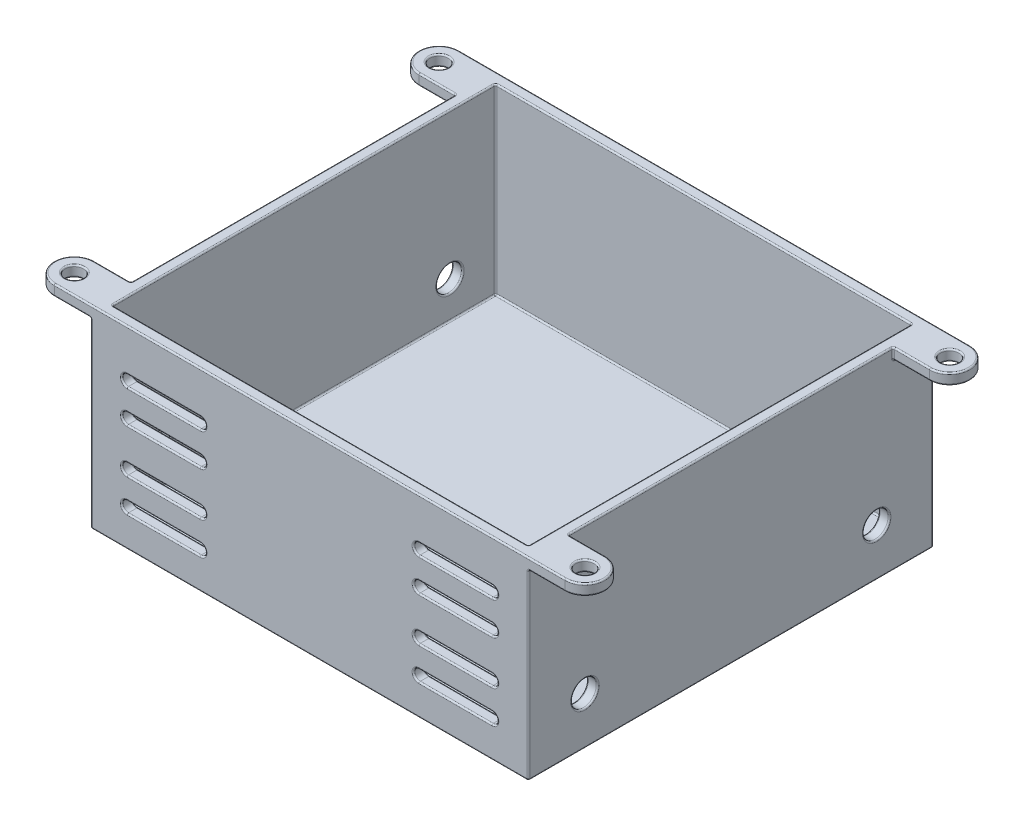
from build123d import *

# Parameters (mm, degrees)
SKETCH8_W                      = 60
SKETCH8_H                      = 55.5
SKETCH8_W_2                    = 57
SKETCH8_H_2                    = 52.5
BOSS_EXTRUDE4_DEPTH            = 25
SKETCH9_W                      = 60
SKETCH9_H                      = 55.5
BOSS_EXTRUDE5_DEPTH            = 1.5
SKETCH10_R                     = 1.25
BOSS_EXTRUDE6_DEPTH            = 1.5
CUT_EXTRUDE1_REACH             = 29.75
CUT_EXTRUDE1_DIRECTION_2_REACH = 29.75
CUT_EXTRUDE2_REACH             = 39.75
SKETCH14_R                     = 1.75
CUT_EXTRUDE2_DIRECTION_2_REACH = 39.75
FILLET1_R                      = 0.2


with BuildPart() as part:
    # Sketch8 → Boss-Extrude4 (new body)
    with BuildSketch(Plane(origin=(0, 0, 0), x_dir=(1, 0, 0), z_dir=(0, 1, 0))):
        Rectangle(SKETCH8_W, SKETCH8_H)
        Rectangle(SKETCH8_W_2, SKETCH8_H_2, mode=Mode.SUBTRACT)
    extrude(amount=-BOSS_EXTRUDE4_DEPTH)

    # Sketch9 → Boss-Extrude5 (add)
    with BuildSketch(Plane.XZ.offset(25)):
        Rectangle(SKETCH9_W, SKETCH9_H)
    extrude(amount=BOSS_EXTRUDE5_DEPTH)

    # Sketch10 → Boss-Extrude6 (add)
    with BuildSketch(Plane(origin=(0, 0, 0), x_dir=(1, 0, 0), z_dir=(0, 1, 0))):
        with BuildLine():
            Line((-30, -22.25), (-30, -27.75))
            Line((-30, -27.75), (-35, -27.75))
            ThreePointArc((-35, -27.75), (-37.75, -25), (-35, -22.25))
            Line((-35, -22.25), (-30, -22.25))
        make_face()
        with Locations((-35, -25)):
            Circle(SKETCH10_R, mode=Mode.SUBTRACT)
        with BuildLine():
            Line((30, -27.75), (30, -22.25))
            Line((30, -22.25), (35, -22.25))
            ThreePointArc((35, -22.25), (37.75, -25), (35, -27.75))
            Line((35, -27.75), (30, -27.75))
        make_face()
        with Locations((35, -25)):
            Circle(SKETCH10_R, mode=Mode.SUBTRACT)
        with BuildLine():
            Line((35, 22.25), (30, 22.25))
            Line((30, 22.25), (30, 27.75))
            Line((30, 27.75), (35, 27.75))
            ThreePointArc((35, 27.75), (37.75, 25), (35, 22.25))
        make_face()
        with Locations((35, 25)):
            Circle(SKETCH10_R, mode=Mode.SUBTRACT)
        with BuildLine():
            Line((-35, 22.25), (-30, 22.25))
            Line((-30, 22.25), (-30, 27.75))
            Line((-30, 27.75), (-35, 27.75))
            ThreePointArc((-35, 27.75), (-37.75, 25), (-35, 22.25))
        make_face()
        with Locations((-35, 25)):
            Circle(SKETCH10_R, mode=Mode.SUBTRACT)
    extrude(amount=-BOSS_EXTRUDE6_DEPTH)

    # Cut-Extrude1: up to this face of the body (flat: up to its plane)
    cut_extrude1_end = Plane(part.part.faces().sort_by_distance((0, -13.13317757, 27.75))[0])
    # Sketch13 → Cut-Extrude1 (cut, up to the picked face)
    with BuildSketch(Plane.XY, mode=Mode.PRIVATE) as cut_extrude1_sk1:
        with BuildLine():
            Line((-25, -5.75), (-15, -5.75))
            ThreePointArc((-15, -5.75), (-14.25, -6.5), (-15, -7.25))
            Line((-15, -7.25), (-25, -7.25))
            ThreePointArc((-25, -7.25), (-25.75, -6.5), (-25, -5.75))
        make_face()
    cut_extrude1_tool1 = split(extrude(cut_extrude1_sk1.sketch, amount=CUT_EXTRUDE1_REACH, mode=Mode.PRIVATE), bisect_by=cut_extrude1_end, keep=Keep.BOTH, mode=Mode.PRIVATE)
    add(cut_extrude1_tool1.solids().sort_by_distance((-20, -6.5, 0))[0], mode=Mode.SUBTRACT)
    # Sketch13 → Cut-Extrude1 (cut, up to the picked face)
    with BuildSketch(Plane.XY, mode=Mode.PRIVATE) as cut_extrude1_sk2:
        with BuildLine():
            Line((-25, -10.25), (-15, -10.25))
            ThreePointArc((-15, -10.25), (-14.25, -11), (-15, -11.75))
            Line((-15, -11.75), (-25, -11.75))
            ThreePointArc((-25, -11.75), (-25.75, -11), (-25, -10.25))
        make_face()
    cut_extrude1_tool2 = split(extrude(cut_extrude1_sk2.sketch, amount=CUT_EXTRUDE1_REACH, mode=Mode.PRIVATE), bisect_by=cut_extrude1_end, keep=Keep.BOTH, mode=Mode.PRIVATE)
    add(cut_extrude1_tool2.solids().sort_by_distance((-20, -11, 0))[0], mode=Mode.SUBTRACT)
    # Sketch13 → Cut-Extrude1 (cut, up to the picked face)
    with BuildSketch(Plane.XY, mode=Mode.PRIVATE) as cut_extrude1_sk3:
        with BuildLine():
            Line((-25, -22.25), (-15, -22.25))
            ThreePointArc((-15, -22.25), (-14.25, -21.5), (-15, -20.75))
            Line((-15, -20.75), (-25, -20.75))
            ThreePointArc((-25, -20.75), (-25.75, -21.5), (-25, -22.25))
        make_face()
    cut_extrude1_tool3 = split(extrude(cut_extrude1_sk3.sketch, amount=CUT_EXTRUDE1_REACH, mode=Mode.PRIVATE), bisect_by=cut_extrude1_end, keep=Keep.BOTH, mode=Mode.PRIVATE)
    add(cut_extrude1_tool3.solids().sort_by_distance((-20, -21.5, 0))[0], mode=Mode.SUBTRACT)
    # Sketch13 → Cut-Extrude1 (cut, up to the picked face)
    with BuildSketch(Plane.XY, mode=Mode.PRIVATE) as cut_extrude1_sk4:
        with BuildLine():
            Line((-25, -17.75), (-15, -17.75))
            ThreePointArc((-15, -17.75), (-14.25, -17), (-15, -16.25))
            Line((-15, -16.25), (-25, -16.25))
            ThreePointArc((-25, -16.25), (-25.75, -17), (-25, -17.75))
        make_face()
    cut_extrude1_tool4 = split(extrude(cut_extrude1_sk4.sketch, amount=CUT_EXTRUDE1_REACH, mode=Mode.PRIVATE), bisect_by=cut_extrude1_end, keep=Keep.BOTH, mode=Mode.PRIVATE)
    add(cut_extrude1_tool4.solids().sort_by_distance((-20, -17, 0))[0], mode=Mode.SUBTRACT)
    # Sketch13 → Cut-Extrude1 (cut, up to the picked face)
    with BuildSketch(Plane.XY, mode=Mode.PRIVATE) as cut_extrude1_sk5:
        with BuildLine():
            Line((25, -5.75), (15, -5.75))
            ThreePointArc((15, -5.75), (14.25, -6.5), (15, -7.25))
            Line((15, -7.25), (25, -7.25))
            ThreePointArc((25, -7.25), (25.75, -6.5), (25, -5.75))
        make_face()
    cut_extrude1_tool5 = split(extrude(cut_extrude1_sk5.sketch, amount=CUT_EXTRUDE1_REACH, mode=Mode.PRIVATE), bisect_by=cut_extrude1_end, keep=Keep.BOTH, mode=Mode.PRIVATE)
    add(cut_extrude1_tool5.solids().sort_by_distance((20, -6.5, 0))[0], mode=Mode.SUBTRACT)
    # Sketch13 → Cut-Extrude1 (cut, up to the picked face)
    with BuildSketch(Plane.XY, mode=Mode.PRIVATE) as cut_extrude1_sk6:
        with BuildLine():
            Line((25, -10.25), (15, -10.25))
            ThreePointArc((15, -10.25), (14.25, -11), (15, -11.75))
            Line((15, -11.75), (25, -11.75))
            ThreePointArc((25, -11.75), (25.75, -11), (25, -10.25))
        make_face()
    cut_extrude1_tool6 = split(extrude(cut_extrude1_sk6.sketch, amount=CUT_EXTRUDE1_REACH, mode=Mode.PRIVATE), bisect_by=cut_extrude1_end, keep=Keep.BOTH, mode=Mode.PRIVATE)
    add(cut_extrude1_tool6.solids().sort_by_distance((20, -11, 0))[0], mode=Mode.SUBTRACT)
    # Sketch13 → Cut-Extrude1 (cut, up to the picked face)
    with BuildSketch(Plane.XY, mode=Mode.PRIVATE) as cut_extrude1_sk7:
        with BuildLine():
            Line((25, -22.25), (15, -22.25))
            ThreePointArc((15, -22.25), (14.25, -21.5), (15, -20.75))
            Line((15, -20.75), (25, -20.75))
            ThreePointArc((25, -20.75), (25.75, -21.5), (25, -22.25))
        make_face()
    cut_extrude1_tool7 = split(extrude(cut_extrude1_sk7.sketch, amount=CUT_EXTRUDE1_REACH, mode=Mode.PRIVATE), bisect_by=cut_extrude1_end, keep=Keep.BOTH, mode=Mode.PRIVATE)
    add(cut_extrude1_tool7.solids().sort_by_distance((20, -21.5, 0))[0], mode=Mode.SUBTRACT)
    # Sketch13 → Cut-Extrude1 (cut, up to the picked face)
    with BuildSketch(Plane.XY, mode=Mode.PRIVATE) as cut_extrude1_sk8:
        with BuildLine():
            Line((25, -17.75), (15, -17.75))
            ThreePointArc((15, -17.75), (14.25, -17), (15, -16.25))
            Line((15, -16.25), (25, -16.25))
            ThreePointArc((25, -16.25), (25.75, -17), (25, -17.75))
        make_face()
    cut_extrude1_tool8 = split(extrude(cut_extrude1_sk8.sketch, amount=CUT_EXTRUDE1_REACH, mode=Mode.PRIVATE), bisect_by=cut_extrude1_end, keep=Keep.BOTH, mode=Mode.PRIVATE)
    add(cut_extrude1_tool8.solids().sort_by_distance((20, -17, 0))[0], mode=Mode.SUBTRACT)

    # Cut-Extrude1 direction 2: up to this face of the body (flat: up to its plane)
    cut_extrude1_direction_2_end = Plane(part.part.faces().sort_by_distance((0, -12.5, -26.25))[0])
    # Sketch13 → Cut-Extrude1 direction 2 (cut, up to the picked face)
    with BuildSketch(Plane.XY, mode=Mode.PRIVATE) as cut_extrude1_direction_2_sk1:
        with BuildLine():
            Line((-25, -5.75), (-15, -5.75))
            ThreePointArc((-15, -5.75), (-14.25, -6.5), (-15, -7.25))
            Line((-15, -7.25), (-25, -7.25))
            ThreePointArc((-25, -7.25), (-25.75, -6.5), (-25, -5.75))
        make_face()
    cut_extrude1_direction_2_tool1 = split(extrude(cut_extrude1_direction_2_sk1.sketch, amount=-CUT_EXTRUDE1_DIRECTION_2_REACH, mode=Mode.PRIVATE), bisect_by=cut_extrude1_direction_2_end, keep=Keep.BOTH, mode=Mode.PRIVATE)
    add(cut_extrude1_direction_2_tool1.solids().sort_by_distance((-20, -6.5, 0))[0], mode=Mode.SUBTRACT)
    # Sketch13 → Cut-Extrude1 direction 2 (cut, up to the picked face)
    with BuildSketch(Plane.XY, mode=Mode.PRIVATE) as cut_extrude1_direction_2_sk2:
        with BuildLine():
            Line((-25, -10.25), (-15, -10.25))
            ThreePointArc((-15, -10.25), (-14.25, -11), (-15, -11.75))
            Line((-15, -11.75), (-25, -11.75))
            ThreePointArc((-25, -11.75), (-25.75, -11), (-25, -10.25))
        make_face()
    cut_extrude1_direction_2_tool2 = split(extrude(cut_extrude1_direction_2_sk2.sketch, amount=-CUT_EXTRUDE1_DIRECTION_2_REACH, mode=Mode.PRIVATE), bisect_by=cut_extrude1_direction_2_end, keep=Keep.BOTH, mode=Mode.PRIVATE)
    add(cut_extrude1_direction_2_tool2.solids().sort_by_distance((-20, -11, 0))[0], mode=Mode.SUBTRACT)
    # Sketch13 → Cut-Extrude1 direction 2 (cut, up to the picked face)
    with BuildSketch(Plane.XY, mode=Mode.PRIVATE) as cut_extrude1_direction_2_sk3:
        with BuildLine():
            Line((-25, -22.25), (-15, -22.25))
            ThreePointArc((-15, -22.25), (-14.25, -21.5), (-15, -20.75))
            Line((-15, -20.75), (-25, -20.75))
            ThreePointArc((-25, -20.75), (-25.75, -21.5), (-25, -22.25))
        make_face()
    cut_extrude1_direction_2_tool3 = split(extrude(cut_extrude1_direction_2_sk3.sketch, amount=-CUT_EXTRUDE1_DIRECTION_2_REACH, mode=Mode.PRIVATE), bisect_by=cut_extrude1_direction_2_end, keep=Keep.BOTH, mode=Mode.PRIVATE)
    add(cut_extrude1_direction_2_tool3.solids().sort_by_distance((-20, -21.5, 0))[0], mode=Mode.SUBTRACT)
    # Sketch13 → Cut-Extrude1 direction 2 (cut, up to the picked face)
    with BuildSketch(Plane.XY, mode=Mode.PRIVATE) as cut_extrude1_direction_2_sk4:
        with BuildLine():
            Line((-25, -17.75), (-15, -17.75))
            ThreePointArc((-15, -17.75), (-14.25, -17), (-15, -16.25))
            Line((-15, -16.25), (-25, -16.25))
            ThreePointArc((-25, -16.25), (-25.75, -17), (-25, -17.75))
        make_face()
    cut_extrude1_direction_2_tool4 = split(extrude(cut_extrude1_direction_2_sk4.sketch, amount=-CUT_EXTRUDE1_DIRECTION_2_REACH, mode=Mode.PRIVATE), bisect_by=cut_extrude1_direction_2_end, keep=Keep.BOTH, mode=Mode.PRIVATE)
    add(cut_extrude1_direction_2_tool4.solids().sort_by_distance((-20, -17, 0))[0], mode=Mode.SUBTRACT)
    # Sketch13 → Cut-Extrude1 direction 2 (cut, up to the picked face)
    with BuildSketch(Plane.XY, mode=Mode.PRIVATE) as cut_extrude1_direction_2_sk5:
        with BuildLine():
            Line((25, -5.75), (15, -5.75))
            ThreePointArc((15, -5.75), (14.25, -6.5), (15, -7.25))
            Line((15, -7.25), (25, -7.25))
            ThreePointArc((25, -7.25), (25.75, -6.5), (25, -5.75))
        make_face()
    cut_extrude1_direction_2_tool5 = split(extrude(cut_extrude1_direction_2_sk5.sketch, amount=-CUT_EXTRUDE1_DIRECTION_2_REACH, mode=Mode.PRIVATE), bisect_by=cut_extrude1_direction_2_end, keep=Keep.BOTH, mode=Mode.PRIVATE)
    add(cut_extrude1_direction_2_tool5.solids().sort_by_distance((20, -6.5, 0))[0], mode=Mode.SUBTRACT)
    # Sketch13 → Cut-Extrude1 direction 2 (cut, up to the picked face)
    with BuildSketch(Plane.XY, mode=Mode.PRIVATE) as cut_extrude1_direction_2_sk6:
        with BuildLine():
            Line((25, -10.25), (15, -10.25))
            ThreePointArc((15, -10.25), (14.25, -11), (15, -11.75))
            Line((15, -11.75), (25, -11.75))
            ThreePointArc((25, -11.75), (25.75, -11), (25, -10.25))
        make_face()
    cut_extrude1_direction_2_tool6 = split(extrude(cut_extrude1_direction_2_sk6.sketch, amount=-CUT_EXTRUDE1_DIRECTION_2_REACH, mode=Mode.PRIVATE), bisect_by=cut_extrude1_direction_2_end, keep=Keep.BOTH, mode=Mode.PRIVATE)
    add(cut_extrude1_direction_2_tool6.solids().sort_by_distance((20, -11, 0))[0], mode=Mode.SUBTRACT)
    # Sketch13 → Cut-Extrude1 direction 2 (cut, up to the picked face)
    with BuildSketch(Plane.XY, mode=Mode.PRIVATE) as cut_extrude1_direction_2_sk7:
        with BuildLine():
            Line((25, -22.25), (15, -22.25))
            ThreePointArc((15, -22.25), (14.25, -21.5), (15, -20.75))
            Line((15, -20.75), (25, -20.75))
            ThreePointArc((25, -20.75), (25.75, -21.5), (25, -22.25))
        make_face()
    cut_extrude1_direction_2_tool7 = split(extrude(cut_extrude1_direction_2_sk7.sketch, amount=-CUT_EXTRUDE1_DIRECTION_2_REACH, mode=Mode.PRIVATE), bisect_by=cut_extrude1_direction_2_end, keep=Keep.BOTH, mode=Mode.PRIVATE)
    add(cut_extrude1_direction_2_tool7.solids().sort_by_distance((20, -21.5, 0))[0], mode=Mode.SUBTRACT)
    # Sketch13 → Cut-Extrude1 direction 2 (cut, up to the picked face)
    with BuildSketch(Plane.XY, mode=Mode.PRIVATE) as cut_extrude1_direction_2_sk8:
        with BuildLine():
            Line((25, -17.75), (15, -17.75))
            ThreePointArc((15, -17.75), (14.25, -17), (15, -16.25))
            Line((15, -16.25), (25, -16.25))
            ThreePointArc((25, -16.25), (25.75, -17), (25, -17.75))
        make_face()
    cut_extrude1_direction_2_tool8 = split(extrude(cut_extrude1_direction_2_sk8.sketch, amount=-CUT_EXTRUDE1_DIRECTION_2_REACH, mode=Mode.PRIVATE), bisect_by=cut_extrude1_direction_2_end, keep=Keep.BOTH, mode=Mode.PRIVATE)
    add(cut_extrude1_direction_2_tool8.solids().sort_by_distance((20, -17, 0))[0], mode=Mode.SUBTRACT)

    # Cut-Extrude2: up to this face of the body (flat: up to its plane)
    cut_extrude2_end = Plane(part.part.faces().sort_by_distance((30, -13.391825683, 0))[0])
    # Sketch14 → Cut-Extrude2 (cut, up to the picked face)
    with BuildSketch(Plane(origin=(0, 0, 0), x_dir=(0, 0, -1), z_dir=(1, 0, 0)), mode=Mode.PRIVATE) as cut_extrude2_sk1:
        with Locations((-20, -20)):
            Circle(SKETCH14_R)
    cut_extrude2_tool1 = split(extrude(cut_extrude2_sk1.sketch, amount=CUT_EXTRUDE2_REACH, mode=Mode.PRIVATE), bisect_by=cut_extrude2_end, keep=Keep.BOTH, mode=Mode.PRIVATE)
    add(cut_extrude2_tool1.solids().sort_by_distance((0, -20, 20))[0], mode=Mode.SUBTRACT)
    # Sketch14 → Cut-Extrude2 (cut, up to the picked face)
    with BuildSketch(Plane(origin=(0, 0, 0), x_dir=(0, 0, -1), z_dir=(1, 0, 0)), mode=Mode.PRIVATE) as cut_extrude2_sk2:
        with Locations((20, -20)):
            Circle(SKETCH14_R)
    cut_extrude2_tool2 = split(extrude(cut_extrude2_sk2.sketch, amount=CUT_EXTRUDE2_REACH, mode=Mode.PRIVATE), bisect_by=cut_extrude2_end, keep=Keep.BOTH, mode=Mode.PRIVATE)
    add(cut_extrude2_tool2.solids().sort_by_distance((0, -20, -20))[0], mode=Mode.SUBTRACT)

    # Cut-Extrude2 direction 2: up to this face of the body (flat: up to its plane)
    cut_extrude2_direction_2_end = Plane(part.part.faces().sort_by_distance((-30, -13.391825683, 0))[0])
    # Sketch14 → Cut-Extrude2 direction 2 (cut, up to the picked face)
    with BuildSketch(Plane(origin=(0, 0, 0), x_dir=(0, 0, -1), z_dir=(1, 0, 0)), mode=Mode.PRIVATE) as cut_extrude2_direction_2_sk1:
        with Locations((-20, -20)):
            Circle(SKETCH14_R)
    cut_extrude2_direction_2_tool1 = split(extrude(cut_extrude2_direction_2_sk1.sketch, amount=-CUT_EXTRUDE2_DIRECTION_2_REACH, mode=Mode.PRIVATE), bisect_by=cut_extrude2_direction_2_end, keep=Keep.BOTH, mode=Mode.PRIVATE)
    add(cut_extrude2_direction_2_tool1.solids().sort_by_distance((0, -20, 20))[0], mode=Mode.SUBTRACT)
    # Sketch14 → Cut-Extrude2 direction 2 (cut, up to the picked face)
    with BuildSketch(Plane(origin=(0, 0, 0), x_dir=(0, 0, -1), z_dir=(1, 0, 0)), mode=Mode.PRIVATE) as cut_extrude2_direction_2_sk2:
        with Locations((20, -20)):
            Circle(SKETCH14_R)
    cut_extrude2_direction_2_tool2 = split(extrude(cut_extrude2_direction_2_sk2.sketch, amount=-CUT_EXTRUDE2_DIRECTION_2_REACH, mode=Mode.PRIVATE), bisect_by=cut_extrude2_direction_2_end, keep=Keep.BOTH, mode=Mode.PRIVATE)
    add(cut_extrude2_direction_2_tool2.solids().sort_by_distance((0, -20, -20))[0], mode=Mode.SUBTRACT)

    # Fillet1
    fillet1_edges = [part.edges().sort_by_distance(p)[0] for p in [
        (28.5, -25, 0),
        (25.75, -6.5, 26.25),
        (20, -5.75, 26.25),
        (14.25, -6.5, 26.25),
        (20, -7.25, 26.25),
        (20, -7.25, 27.75),
        (25.75, -6.5, 27.75),
        (20, -5.75, 27.75),
        (14.25, -6.5, 27.75),
        (28.5, -12.5, -26.25),
        (0, -25, 26.25),
        (28.5, -12.5, 26.25),
        (-25.75, -17, 26.25),
        (-28.5, -25, 0),
        (-20, -17.75, 26.25),
        (-14.25, -17, 26.25),
        (-20, -16.25, 26.25),
        (-20, -16.25, 27.75),
        (-25.75, -17, 27.75),
        (-20, -17.75, 27.75),
        (-14.25, -17, 27.75),
        (-28.5, -12.5, 26.25),
        (0, -25, -26.25),
        (-28.5, -12.5, -26.25),
        (-25.75, -21.5, 26.25),
        (-20, -22.25, 26.25),
        (-14.25, -21.5, 26.25),
        (28.5, 0, 0),
        (-20, -20.75, 26.25),
        (-20, -20.75, 27.75),
        (-25.75, -21.5, 27.75),
        (-20, -22.25, 27.75),
        (-14.25, -21.5, 27.75),
        (0, 0, -26.25),
        (-28.5, 0, 0),
        (-25.75, -11, 26.25),
        (-20, -11.75, 26.25),
        (-14.25, -11, 26.25),
        (-20, -10.25, 26.25),
        (-20, -10.25, 27.75),
        (-25.75, -11, 27.75),
        (-20, -11.75, 27.75),
        (-14.25, -11, 27.75),
        (0, 0, 26.25),
        (25.75, -17, 26.25),
        (20, -16.25, 26.25),
        (14.25, -17, 26.25),
        (20, -17.75, 26.25),
        (20, -17.75, 27.75),
        (25.75, -17, 27.75),
        (20, -16.25, 27.75),
        (14.25, -17, 27.75),
        (25.75, -21.5, 26.25),
        (20, -20.75, 26.25),
        (14.25, -21.5, 26.25),
        (20, -22.25, 26.25),
        (20, -22.25, 27.75),
        (25.75, -21.5, 27.75),
        (20, -20.75, 27.75),
        (14.25, -21.5, 27.75),
        (25.75, -11, 26.25),
        (20, -10.25, 26.25),
        (14.25, -11, 26.25),
        (20, -11.75, 26.25),
        (20, -11.75, 27.75),
        (25.75, -11, 27.75),
        (20, -10.25, 27.75),
        (14.25, -11, 27.75),
        (-25.75, -6.5, 26.25),
        (-20, -7.25, 26.25),
        (-14.25, -6.5, 26.25),
        (-20, -5.75, 26.25),
        (-20, -5.75, 27.75),
        (-25.75, -6.5, 27.75),
        (-20, -7.25, 27.75),
        (-14.25, -6.5, 27.75),
        (-30, -20, 21.75),
        (28.5, -20, 21.75),
        (-28.5, -20, 21.75),
        (30, -20, 21.75),
        (-30, -20, -18.25),
        (28.5, -20, -18.25),
        (-28.5, -20, -18.25),
        (30, -20, -18.25),
        (0, -26.5, 27.75),
        (-30, -26.5, 0),
        (0, -26.5, -27.75),
        (30, -26.5, 0),
        (-30, 0, 0),
        (-30, -1.5, -25),
        (-32.5, -1.5, -22.25),
        (-30, -0.75, -22.25),
        (-37.75, -1.5, -25),
        (-32.5, -1.5, -27.75),
        (-36.25, -1.5, -25),
        (0, 0, -27.75),
        (-37.75, 0, -25),
        (-32.5, 0, -22.25),
        (-36.25, 0, -25),
        (0, 0, 27.75),
        (-32.5, -1.5, 27.75),
        (-37.75, -1.5, 25),
        (-32.5, -1.5, 22.25),
        (-30, -1.5, 25),
        (-30, -0.75, 22.25),
        (-36.25, -1.5, 25),
        (-32.5, 0, 22.25),
        (-37.75, 0, 25),
        (-36.25, 0, 25),
        (37.75, -1.5, -25),
        (32.5, -1.5, -22.25),
        (30, -1.5, -25),
        (30, -0.75, -22.25),
        (32.5, -1.5, -27.75),
        (33.75, -1.5, -25),
        (37.75, 0, -25),
        (32.5, 0, -22.25),
        (33.75, 0, -25),
        (-30, -14, -27.75),
        (30, -14, -27.75),
        (30, -14, 27.75),
        (-30, -14, 27.75),
        (30, 0, 0),
        (32.5, -1.5, 27.75),
        (30, -1.5, 25),
        (32.5, -1.5, 22.25),
        (30, -0.75, 22.25),
        (37.75, -1.5, 25),
        (33.75, -1.5, 25),
        (37.75, 0, 25),
        (32.5, 0, 22.25),
        (33.75, 0, 25),
    ]]
    fillet(fillet1_edges, radius=FILLET1_R)


solid = part.part
